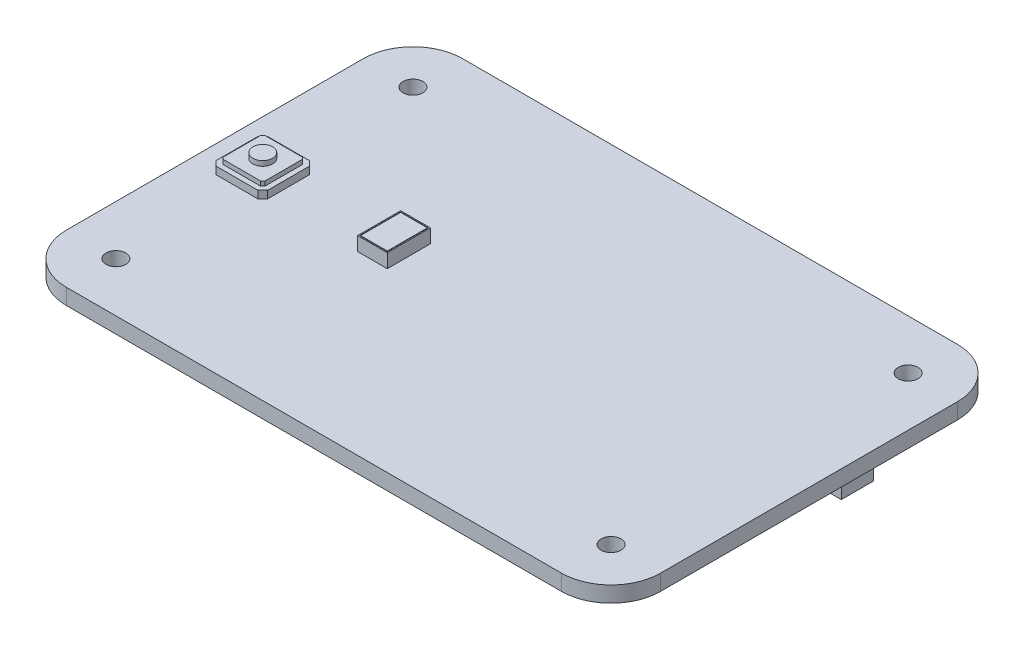
from build123d import *

# Parameters (mm, degrees)
SKETCH1_W              = 60
SKETCH1_H              = 40
BOSS_EXTRUDE1_DEPTH    = 1.6
SKETCH2_R              = 1
CUT_EXTRUDE1_DEPTH     = 37.090996107
FILLET1_R              = 5
CUT_EXTRUDE2_START     = -0.5
SKETCH4_W              = 0.8
SKETCH4_H              = 0.3
SKETCH4_W_2            = 1.1
CUT_EXTRUDE2_DEPTH     = 36.590996107
SKETCH5_W              = 6
SKETCH5_H              = 11.4
BOSS_EXTRUDE2_DEPTH    = 2
CUT_EXTRUDE3_DEPTH     = 0.5
SKETCH6_3_W            = 0.064917345
SKETCH6_3_H            = 11.4
CUT_EXTRUDE4_DEPTH     = 1.75
BOSS_EXTRUDE3_DEPTH    = 0.75
BOSS_EXTRUDE4_DEPTH    = 0.45
SKETCH9_W              = 3
SKETCH9_H              = 4.35
BOSS_EXTRUDE6_DEPTH    = 1.4
SKETCH10_W             = 2.8
SKETCH10_H             = 4.15
CUT_EXTRUDE5_DEPTH     = 0.1
SKETCH11_W             = 2.7
SKETCH11_H             = 4.05
BOSS_EXTRUDE7_DEPTH    = 0.1
SKETCH13_W             = 4
SKETCH13_H             = 4
BOSS_EXTRUDE8_DEPTH    = 1.75
SKETCH14_W             = 5.2
SKETCH14_H             = 5.4
BOSS_EXTRUDE9_DEPTH    = 1.5
SKETCH15_W             = 3.8
SKETCH15_H             = 5
BOSS_EXTRUDE10_DEPTH   = 1.5
SKETCH16_W             = 1.65
SKETCH16_H             = 3.25
BOSS_EXTRUDE11_DEPTH   = 1.35
SKETCH17_R             = 1
BOSS_EXTRUDE12_DEPTH   = 0.5
SKETCH19_W             = 0.9
SKETCH19_H             = 1.7
BOSS_EXTRUDE13_DEPTH   = 0.15
BOSS_EXTRUDE13_2_DEPTH = 0.15
BOSS_EXTRUDE13_3_DEPTH = 0.15
BOSS_EXTRUDE13_4_DEPTH = 0.15
SKETCH20_W             = 0.9
SKETCH20_H             = 1.2
BOSS_EXTRUDE14_DEPTH   = 0.25


with BuildPart() as part:
    # Sketch1 → Boss-Extrude1 (new body)
    with BuildSketch(Plane(origin=(0, 0, 0), x_dir=(1, 0, 0), z_dir=(0, 1, 0))):
        Rectangle(SKETCH1_W, SKETCH1_H)
    extrude(amount=BOSS_EXTRUDE1_DEPTH)

    # Sketch2 → Cut-Extrude1 (cut, through all)
    with BuildSketch(Plane(origin=(0, 1.6, 0), x_dir=(1, 0, 0), z_dir=(0, 1, 0))):
        with Locations((-25, 15)):
            Circle(SKETCH2_R)
        with Locations((25, 15)):
            Circle(SKETCH2_R)
        with Locations((25, -15)):
            Circle(SKETCH2_R)
        with Locations((-25, -15)):
            Circle(SKETCH2_R)
    extrude(amount=-CUT_EXTRUDE1_DEPTH, mode=Mode.SUBTRACT)

    # Fillet1
    fillet1_edges = [part.edges().sort_by_distance(p)[0] for p in [
        (-30, 0.8, 20),
        (30, 0.8, 20),
        (30, 0.8, -20),
        (-30, 0.8, -20),
    ]]
    fillet(fillet1_edges, radius=FILLET1_R)

    # Sketch4 → Cut-Extrude2 (cut, through all)
    with BuildSketch(Plane(origin=(0, 1.6, 0), x_dir=(1, 0, 0), z_dir=(0, 1, 0)).offset(CUT_EXTRUDE2_START)):
        with Locations((-29.1, 4.32)):
            Rectangle(SKETCH4_W, SKETCH4_H)
        with Locations((-24.92, 4.32)):
            Rectangle(SKETCH4_W_2, SKETCH4_H)
        with Locations((-24.92, -4.32)):
            Rectangle(SKETCH4_W_2, SKETCH4_H)
        with Locations((-29.1, -4.32)):
            Rectangle(SKETCH4_W, SKETCH4_H)
    extrude(amount=-CUT_EXTRUDE2_DEPTH, mode=Mode.SUBTRACT)


with BuildPart() as body_2:
    # Sketch5 → Boss-Extrude2 (new body)
    with BuildSketch(Plane.XZ):
        with Locations((1.3, 0)):
            Rectangle(SKETCH5_W, SKETCH5_H)
    extrude(amount=BOSS_EXTRUDE2_DEPTH)

    # Sketch6 → Cut-Extrude3 (cut)
    with BuildSketch(Plane.XZ.offset(2)):
        Polygon((2.2, 4.2), (2.2, -4.2), (1.95, -4.2), (1.95, -5.2), (3.8, -5.2), (3.8, 5.2), (1.95, 5.2), (1.95, 4.2), align=None)
    extrude(amount=-CUT_EXTRUDE3_DEPTH, mode=Mode.SUBTRACT)

    # Sketch6_3 → Cut-Extrude4 (cut)
    with BuildSketch(Plane.XZ.offset(2)):
        with Locations((3.832458673, 0)):
            Rectangle(SKETCH6_3_W, SKETCH6_3_H)
    extrude(amount=-CUT_EXTRUDE4_DEPTH, mode=Mode.SUBTRACT)


with BuildPart() as body_3:
    # Sketch7 → Boss-Extrude3 (new body)
    with BuildSketch(Plane(origin=(0, 1.6, 0), x_dir=(1, 0, 0), z_dir=(0, 1, 0))):
        Polygon((-27.27, 2.6), (-23.07, 2.6), (-22.57, 2.1), (-22.57, -2.1), (-23.07, -2.6), (-27.27, -2.6), (-27.77, -2.1), (-27.77, 2.1), align=None)
    extrude(amount=BOSS_EXTRUDE3_DEPTH)

    # Sketch8 → Boss-Extrude4 (add)
    with BuildSketch(Plane(origin=(0, 2.35, 0), x_dir=(1, 0, 0), z_dir=(0, 1, 0))):
        Polygon((-23.277106781, 2.1), (-27.062893219, 2.1), (-27.27, 1.892893219), (-27.27, -1.892893219), (-27.062893219, -2.1), (-23.277106781, -2.1), (-23.07, -1.892893219), (-23.07, 1.892893219), align=None)
    extrude(amount=BOSS_EXTRUDE4_DEPTH)

    # Sketch17 → Boss-Extrude12 (add)
    with BuildSketch(Plane(origin=(0, 2.8, 0), x_dir=(1, 0, 0), z_dir=(0, 1, 0))):
        with Locations((-25.17, 0)):
            Circle(SKETCH17_R)
    extrude(amount=BOSS_EXTRUDE12_DEPTH)


with BuildPart() as body_4:
    # Sketch9 → Boss-Extrude6 (new body)
    with BuildSketch(Plane(origin=(0, 1.6, 0), x_dir=(1, 0, 0), z_dir=(0, 1, 0))):
        with Locations((-11.92, 0)):
            Rectangle(SKETCH9_W, SKETCH9_H)
    extrude(amount=BOSS_EXTRUDE6_DEPTH)

    # Sketch10 → Cut-Extrude5 (cut)
    with BuildSketch(Plane(origin=(0, 3, 0), x_dir=(1, 0, 0), z_dir=(0, 1, 0))):
        with Locations((-11.92, 0)):
            Rectangle(SKETCH10_W, SKETCH10_H)
    extrude(amount=-CUT_EXTRUDE5_DEPTH, mode=Mode.SUBTRACT)


with BuildPart() as body_5:
    # Sketch11 → Boss-Extrude7 (new body)
    with BuildSketch(Plane(origin=(0, 2.9, 0), x_dir=(1, 0, 0), z_dir=(0, 1, 0))):
        with Locations((-11.92, 0)):
            Rectangle(SKETCH11_W, SKETCH11_H)
    extrude(amount=BOSS_EXTRUDE7_DEPTH)


with BuildPart() as body_6:
    # Sketch13 → Boss-Extrude8 (new body)
    with BuildSketch(Plane.XZ):
        with Locations((-14.5, -17)):
            Rectangle(SKETCH13_W, SKETCH13_H)
    extrude(amount=BOSS_EXTRUDE8_DEPTH)


with BuildPart() as body_7:
    # Sketch14 → Boss-Extrude9 (new body)
    with BuildSketch(Plane.XZ):
        with Locations((1.95, -12.4)):
            Rectangle(SKETCH14_W, SKETCH14_H)
    extrude(amount=BOSS_EXTRUDE9_DEPTH)


with BuildPart() as body_8:
    # Sketch15 → Boss-Extrude10 (new body)
    with BuildSketch(Plane.XZ):
        with Locations((-7.3, 11)):
            Rectangle(SKETCH15_W, SKETCH15_H)
    extrude(amount=BOSS_EXTRUDE10_DEPTH)


with BuildPart() as body_9:
    # Sketch16 → Boss-Extrude11 (new body)
    with BuildSketch(Plane.XZ):
        with Locations((28.925, -5.125)):
            Rectangle(SKETCH16_W, SKETCH16_H)
    extrude(amount=BOSS_EXTRUDE11_DEPTH)


with BuildPart() as body_10:
    # Sketch19 → Boss-Extrude13 (new body)
    with BuildSketch(Plane.XZ):
        with Locations((-28.75, 6.32)):
            Rectangle(SKETCH19_W, SKETCH19_H)
    extrude(amount=BOSS_EXTRUDE13_DEPTH)



with BuildPart() as body_11:
    # Sketch19 → Boss-Extrude13 2 (new body)
    with BuildSketch(Plane.XZ):
        with Locations((-27.25, 6.32)):
            Rectangle(SKETCH19_W, SKETCH19_H)
    extrude(amount=BOSS_EXTRUDE13_2_DEPTH)


with BuildPart() as body_12:
    # Sketch19 → Boss-Extrude13 3 (new body)
    with BuildSketch(Plane.XZ):
        with Locations((-27.25, -6.32)):
            Rectangle(SKETCH19_W, SKETCH19_H)
    extrude(amount=BOSS_EXTRUDE13_3_DEPTH)


with BuildPart() as body_13:
    # Sketch19 → Boss-Extrude13 4 (new body)
    with BuildSketch(Plane.XZ):
        with Locations((-28.75, -6.32)):
            Rectangle(SKETCH19_W, SKETCH19_H)
    extrude(amount=BOSS_EXTRUDE13_4_DEPTH)


with BuildPart() as body_10_1:
    add(body_10.part)

    add(body_11.part)  # Boss-Extrude14 merges body 11

    add(body_12.part)  # Boss-Extrude14 merges body 12

    add(body_13.part)  # Boss-Extrude14 merges body 13
    # Sketch20 → Boss-Extrude14 (add)
    with BuildSketch(Plane.XZ.offset(0.15)):
        with Locations((-28.75, 6.32)):
            Rectangle(SKETCH20_W, SKETCH20_H)
        with Locations((-27.25, 6.32)):
            Rectangle(SKETCH20_W, SKETCH20_H)
        with Locations((-27.25, -6.32)):
            Rectangle(SKETCH20_W, SKETCH20_H)
        with Locations((-28.75, -6.32)):
            Rectangle(SKETCH20_W, SKETCH20_H)
    extrude(amount=BOSS_EXTRUDE14_DEPTH)


solid = Compound([part.part, body_2.part, body_3.part, body_4.part, body_5.part, body_6.part, body_7.part, body_8.part, body_9.part, body_10_1.part])
